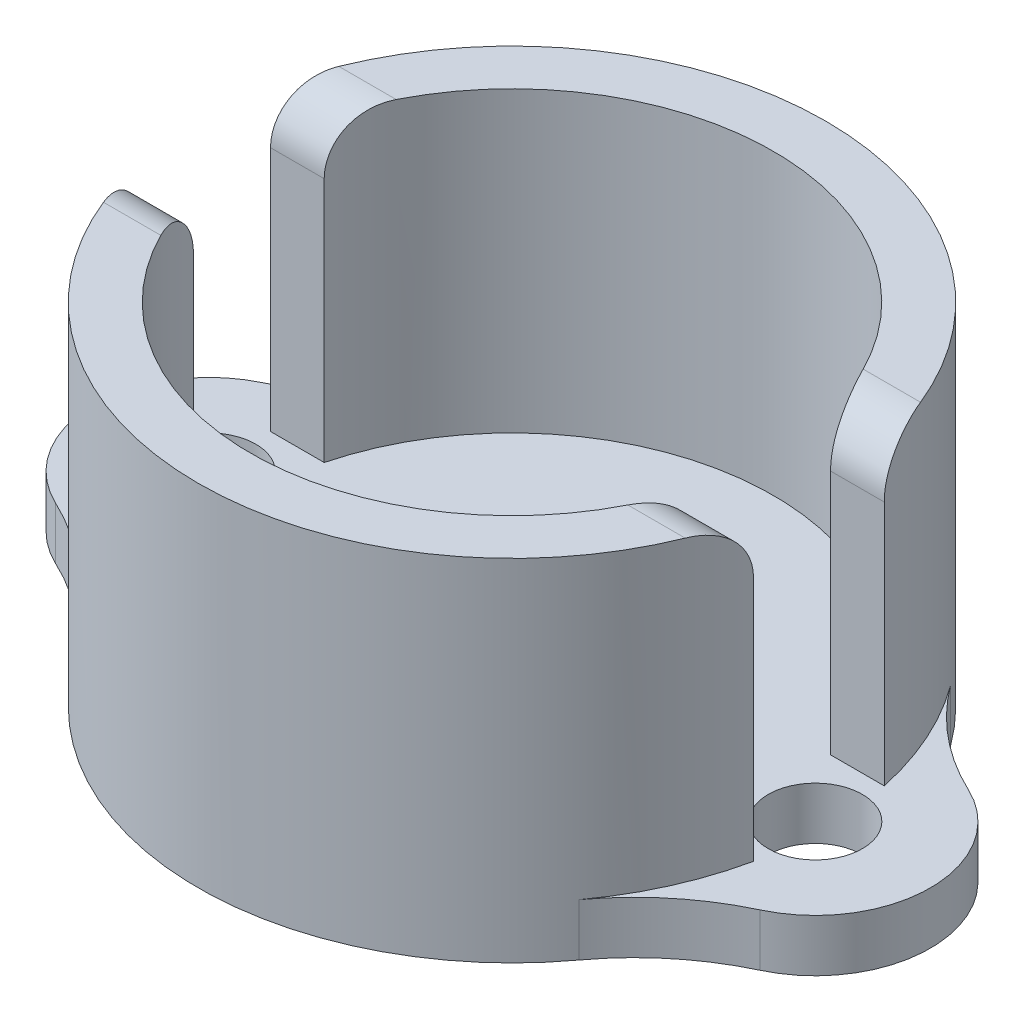
from build123d import *

# Parameters (mm, degrees)
SKETCH1_R           = 3.683
SKETCH1_R_2         = 1.143
BOSS_EXTRUDE1_DEPTH = 1.27
FILLET1_R           = 6.35
BOSS_EXTRUDE2_DEPTH = 7.239
FILLET2_R           = 1.27


with BuildPart() as part:
    # Sketch1 → Boss-Extrude1 (new body)
    with BuildSketch(Plane(origin=(0, 0, 0), x_dir=(1, 0, 0), z_dir=(0, 1, 0))):
        with BuildLine():
            ThreePointArc((-7.094482759, 2.780775861), (-10.16, 0), (-7.094482759, -2.780775861))
            ThreePointArc((-7.094482759, -2.780775861), (0, -7.62), (7.094482759, -2.780775861))
            ThreePointArc((7.094482759, -2.780775861), (10.16, 0), (7.094482759, 2.780775861))
            ThreePointArc((7.094482759, 2.780775861), (0, 7.62), (-7.094482759, 2.780775861))
        make_face()
        Circle(SKETCH1_R, mode=Mode.SUBTRACT)
        with Locations((7.366, 0)):
            Circle(SKETCH1_R_2, mode=Mode.SUBTRACT)
        with Locations((-7.366, 0)):
            Circle(SKETCH1_R_2, mode=Mode.SUBTRACT)
    extrude(amount=BOSS_EXTRUDE1_DEPTH)

    # Fillet1
    fillet1_edges = [part.edges().sort_by_distance(p)[0] for p in [
        (7.094482759, 0.635, -2.780775861),
        (-7.094482759, 0.635, -2.780775861),
        (-7.094482759, 0.635, 2.780775861),
        (7.094482759, 0.635, 2.780775861),
    ]]
    fillet(fillet1_edges, radius=FILLET1_R)

    # Sketch2 → Boss-Extrude2 (add)
    with BuildSketch(Plane(origin=(0, 1.27, 0), x_dir=(1, 0, 0), z_dir=(0, 1, 0))):
        with BuildLine():
            ThreePointArc((7.452801067, 1.5875), (0, 7.62), (-7.452801067, 1.5875))
            Line((-7.452801067, 1.5875), (-6.148361062, 1.5875))
            ThreePointArc((-6.148361062, 1.5875), (0, 6.35), (6.148361062, 1.5875))
            Line((6.148361062, 1.5875), (7.452801067, 1.5875))
        make_face()
        with BuildLine():
            Line((-6.148361062, -1.5875), (-7.452801067, -1.5875))
            ThreePointArc((-7.452801067, -1.5875), (0, -7.62), (7.452801067, -1.5875))
            Line((7.452801067, -1.5875), (6.148361062, -1.5875))
            ThreePointArc((6.148361062, -1.5875), (0, -6.35), (-6.148361062, -1.5875))
        make_face()
    extrude(amount=BOSS_EXTRUDE2_DEPTH)

    # Fillet2
    fillet2_edges = [part.edges().sort_by_distance(p)[0] for p in [
        (6.800581065, 8.509, -1.5875),
        (6.800581065, 8.509, 1.5875),
        (-6.800581065, 8.509, 1.5875),
        (-6.800581065, 8.509, -1.5875),
    ]]
    fillet(fillet2_edges, radius=FILLET2_R)


solid = part.part
